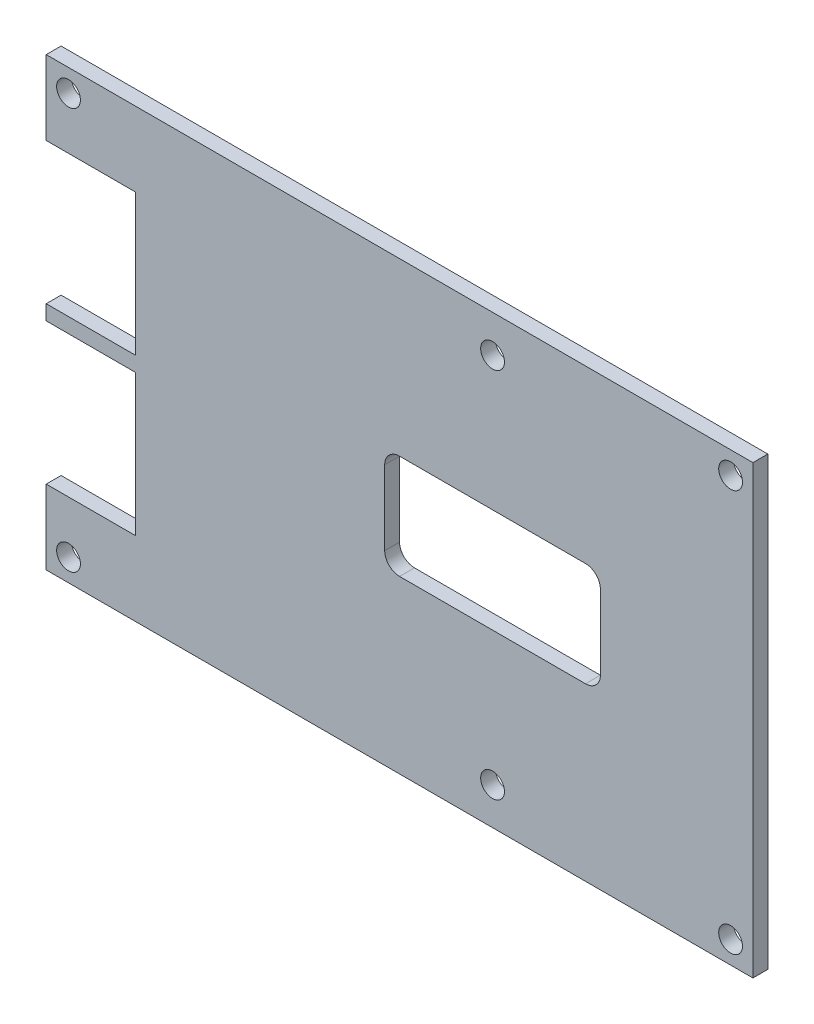
from build123d import *

# Parameters (mm, degrees)
SKETCH1_R           = 1.6
BOSS_EXTRUDE1_DEPTH = 2


with BuildPart() as part:
    # Sketch1 → Boss-Extrude1 (new body)
    with BuildSketch(Plane.XY):
        Polygon((-39.5636369, 18.881491211), (55.4363631, 18.881491211), (55.4363631, -41.118508789), (-39.5636369, -41.118508789), (-39.5636369, -31.118508789), (-27.5636369, -31.118508789), (-27.5636369, -12.118508789), (-39.5636369, -12.118508789), (-39.5636369, -10.118508789), (-27.5636369, -10.118508789), (-27.5636369, 8.881491211), (-39.5636369, 8.881491211), align=None)
        with Locations((20.4363631, 13.881491211)):
            Circle(SKETCH1_R, mode=Mode.SUBTRACT)
        with Locations((20.4363631, -36.118508789)):
            Circle(SKETCH1_R, mode=Mode.SUBTRACT)
        with Locations((-36.5636369, 15.881491211)):
            Circle(SKETCH1_R, mode=Mode.SUBTRACT)
        with Locations((52.4363631, 15.881491211)):
            Circle(SKETCH1_R, mode=Mode.SUBTRACT)
        with Locations((-36.5636369, -38.118508789)):
            Circle(SKETCH1_R, mode=Mode.SUBTRACT)
        with Locations((52.4363631, -38.118508789)):
            Circle(SKETCH1_R, mode=Mode.SUBTRACT)
        with BuildLine():
            Line((7.9363631, -4.118508789), (32.9363631, -4.118508789))
            ThreePointArc((32.9363631, -4.118508789), (34.350576663, -4.704295227), (34.9363631, -6.118508789))
            Line((34.9363631, -6.118508789), (34.9363631, -16.118508789))
            ThreePointArc((34.9363631, -16.118508789), (34.350576663, -17.532722351), (32.9363631, -18.118508789))
            Line((32.9363631, -18.118508789), (7.9363631, -18.118508789))
            ThreePointArc((7.9363631, -18.118508789), (6.522149538, -17.532722351), (5.9363631, -16.118508789))
            Line((5.9363631, -16.118508789), (5.9363631, -6.118508789))
            ThreePointArc((5.9363631, -6.118508789), (6.522149538, -4.704295227), (7.9363631, -4.118508789))
        make_face(mode=Mode.SUBTRACT)
    extrude(amount=BOSS_EXTRUDE1_DEPTH)


solid = part.part
